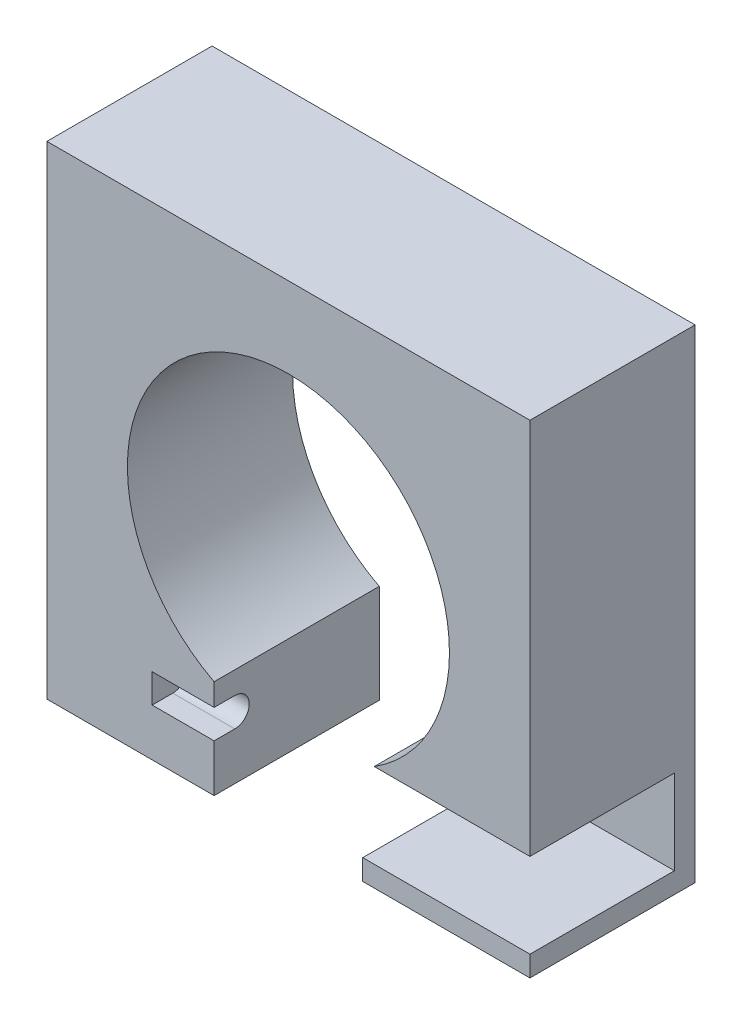
from build123d import *

# Parameters (mm, degrees)
SKETCH_1_W          = 117
SKETCH_1_H          = 117
SKETCH_1_R          = 39
EXTRUDE_1_DEPTH     = 40
CUT_EXTRUDE_1_REACH = 119
SKETCH_2_W          = 36
SKETCH_2_H          = 40
SKETCH_7_W          = 9.65
SKETCH_7_H          = 20.5
CUT_EXTRUDE_4_DEPTH = 40
CUT_EXTRUDE_5_DEPTH = 15
SKETCH_9_W          = 31
SKETCH_9_H          = 20.5
CUT_EXTRUDE_6_DEPTH = 35


with BuildPart() as part:
    # 草圖1 → 填料-伸長1 (new body)
    with BuildSketch(Plane.XY):
        with Locations((4.648877503, -26.451389471)):
            Rectangle(SKETCH_1_W, SKETCH_1_H)
        with Locations((4.648877503, -26.451389471)):
            Circle(SKETCH_1_R, mode=Mode.SUBTRACT)
    extrude(amount=EXTRUDE_1_DEPTH)

    # 草圖2 → 除料-伸長1 (cut, up to next)
    with BuildSketch(Plane.XZ.offset(84.951389471), mode=Mode.PRIVATE) as cut_extrude_1_sk1:
        with Locations((4.648877503, 20)):
            Rectangle(SKETCH_2_W, SKETCH_2_H)
    cut_extrude_1_tool1 = extrude(cut_extrude_1_sk1.sketch, amount=-CUT_EXTRUDE_1_REACH, mode=Mode.PRIVATE) & part.part
    add(cut_extrude_1_tool1.solids().sort_by_distance((4.648878, -84.951389, 20))[0], mode=Mode.SUBTRACT)

    # 草圖7 → 除料-伸長4 (cut)
    with BuildSketch(Plane.XY.offset(40)):
        with Locations((27.473877503, -69.701389471)):
            Rectangle(SKETCH_7_W, SKETCH_7_H)
    extrude(amount=-CUT_EXTRUDE_4_DEPTH, mode=Mode.SUBTRACT)

    # 草圖8 → 除料-伸長5 (cut)
    with BuildSketch(Plane(origin=(-13.351122497, 0, 0), x_dir=(0, 0, -1), z_dir=(1, 0, 0))):
        with BuildLine():
            Line((-40, -66.451389471), (-40, -73.451389471))
            Line((-40, -73.451389471), (-35, -73.451389471))
            ThreePointArc((-35, -73.451389471), (-38.5, -69.951389471), (-35, -66.451389471))
            Line((-35, -66.451389471), (-40, -66.451389471))
        make_face()
        with BuildLine():
            ThreePointArc((-35, -66.451389471), (-38.5, -69.951389471), (-35, -73.451389471))
            Line((-35, -73.451389471), (-35, -66.451389471))
        make_face()
        with BuildLine():
            Line((-35, -66.451389471), (-35, -73.451389471))
            ThreePointArc((-35, -73.451389471), (-32.525126266, -72.426263205), (-31.5, -69.951389471))
            ThreePointArc((-31.5, -69.951389471), (-32.525126266, -67.476515737), (-35, -66.451389471))
        make_face()
    extrude(amount=-CUT_EXTRUDE_5_DEPTH, mode=Mode.SUBTRACT)

    # 草圖9 → 除料-伸長6 (cut)
    with BuildSketch(Plane.XY.offset(40)):
        with Locations((47.798877503, -69.701389471)):
            Rectangle(SKETCH_9_W, SKETCH_9_H)
    extrude(amount=-CUT_EXTRUDE_6_DEPTH, mode=Mode.SUBTRACT)


solid = part.part
